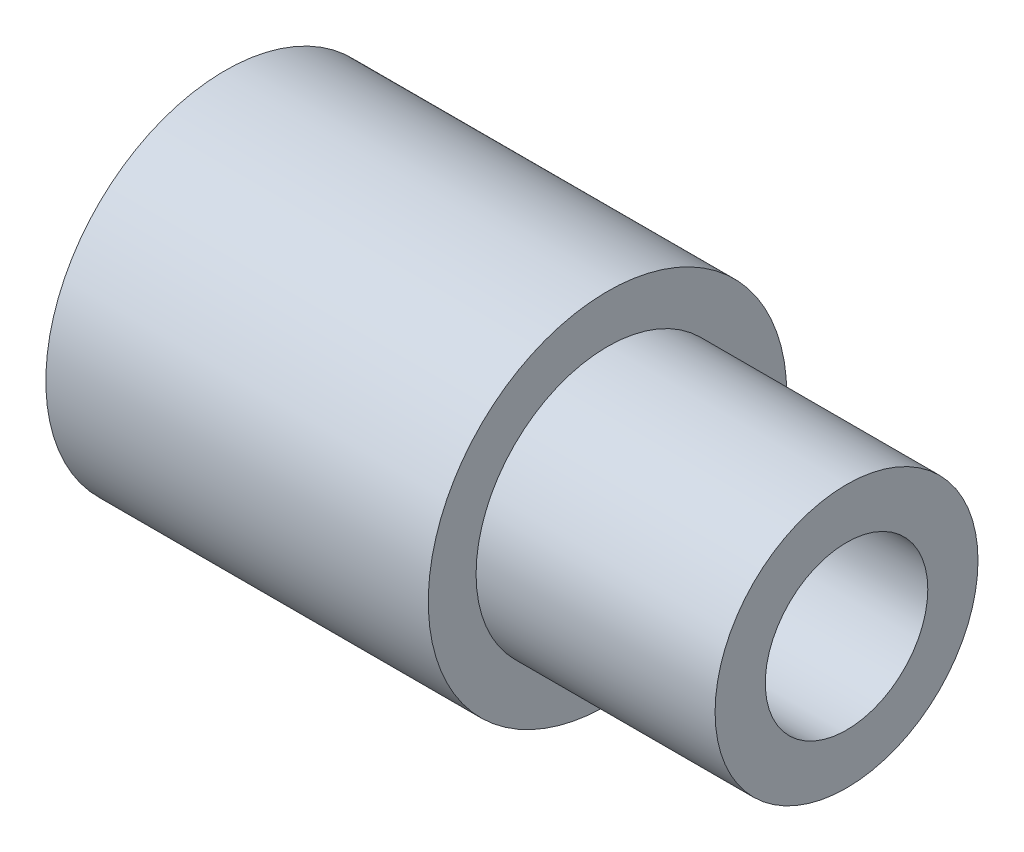
from build123d import *

# Parameters (mm, degrees)
SKETCH_1_R          = 3.75
SKETCH_1_R_2        = 1.7
EXTRUDE_1_DEPTH     = 13
SKETCH_2_R          = 4
SKETCH_2_R_2        = 2.75
CUT_EXTRUDE_1_DEPTH = 5


with BuildPart() as part:
    # 草图1 → 凸台-拉伸1 (new body)
    with BuildSketch(Plane(origin=(0, 0, 0), x_dir=(0, 0, -1), z_dir=(1, 0, 0))):
        Circle(SKETCH_1_R)
        Circle(SKETCH_1_R_2, mode=Mode.SUBTRACT)
    extrude(amount=EXTRUDE_1_DEPTH)

    # 草图2 → 切除-拉伸1 (cut)
    with BuildSketch(Plane(origin=(13, 0, 0), x_dir=(0, 0, -1), z_dir=(1, 0, 0))):
        Circle(SKETCH_2_R)
        Circle(SKETCH_2_R_2, mode=Mode.SUBTRACT)
    extrude(amount=-CUT_EXTRUDE_1_DEPTH, mode=Mode.SUBTRACT)


solid = part.part
